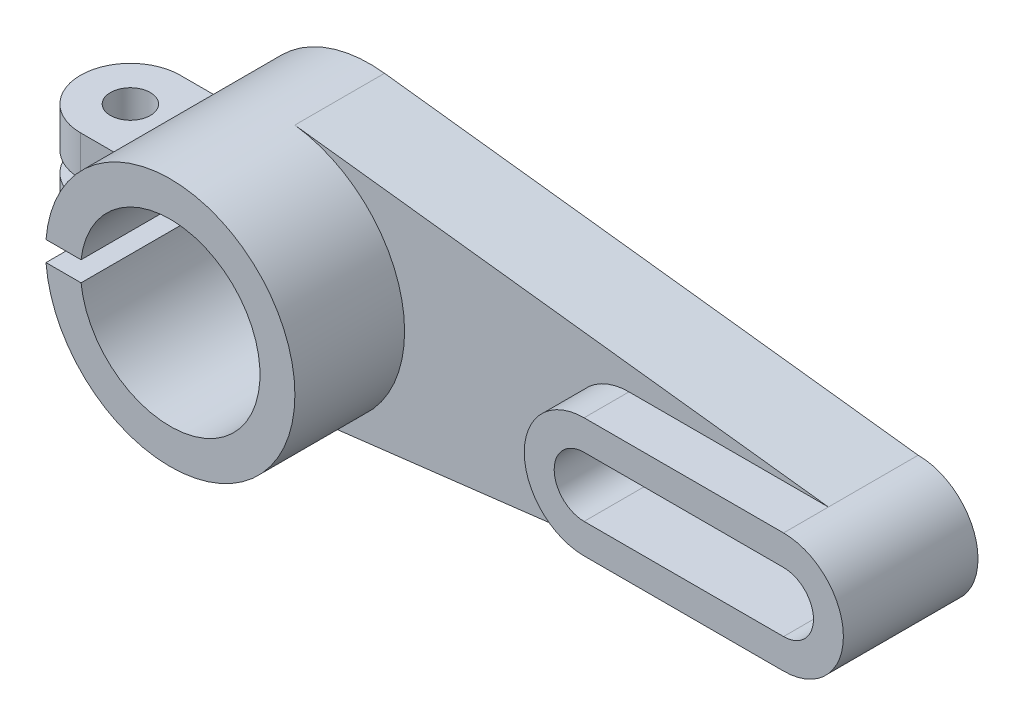
from build123d import *

# Parameters (mm, degrees)
BOSS_EXTRUDE1_DEPTH = 18
BOSS_EXTRUDE2_DEPTH = 9
CUT_EXTRUDE1_DEPTH  = 28
SKETCH3_R           = 25
SKETCH3_R_2         = 18
BOSS_EXTRUDE3_DEPTH = 22
SKETCH3_2_R         = 18
CUT_EXTRUDE2_DEPTH  = 41
SKETCH6_R           = 4
BOSS_EXTRUDE5_DEPTH = 10
SKETCH7_W           = 57.081853501
SKETCH7_H           = 4
CUT_EXTRUDE3_DEPTH  = 40


with BuildPart() as part:
    # Sketch1 → Boss-Extrude1 (new body)
    with BuildSketch(Plane.XY):
        with BuildLine():
            Line((110, 12), (2.973910519, 24.822486906))
            ThreePointArc((2.973910519, 24.822486906), (-25, 0), (2.973910519, -24.822486906))
            Line((2.973910519, -24.822486906), (110, -12))
            ThreePointArc((110, -12), (122, 0), (110, 12))
        make_face()
    extrude(amount=-BOSS_EXTRUDE1_DEPTH)

    # Sketch2 → Boss-Extrude2 (add)
    with BuildSketch(Plane.XY.offset(9)):
        with BuildLine():
            Line((110, -12), (70, -12))
            ThreePointArc((70, -12), (58, 0), (70, 12))
            Line((70, 12), (110, 12))
            ThreePointArc((110, 12), (122, 0), (110, -12))
        make_face()
        with BuildLine():
            Line((70, 6), (110, 6))
            ThreePointArc((110, 6), (116, 0), (110, -6))
            Line((110, -6), (70, -6))
            ThreePointArc((70, -6), (64, 0), (70, 6))
        make_face(mode=Mode.SUBTRACT)
    extrude(amount=-BOSS_EXTRUDE2_DEPTH)

    # Sketch2_2 → Cut-Extrude1 (cut, through all)
    with BuildSketch(Plane.XY.offset(9)):
        with BuildLine():
            Line((70, -6), (110, -6))
            ThreePointArc((110, -6), (116, 0), (110, 6))
            Line((110, 6), (70, 6))
            ThreePointArc((70, 6), (64, 0), (70, -6))
        make_face()
    extrude(amount=-CUT_EXTRUDE1_DEPTH, mode=Mode.SUBTRACT)

    # Sketch3 → Boss-Extrude3 (add)
    with BuildSketch(Plane.XY.offset(22)):
        Circle(SKETCH3_R)
        Circle(SKETCH3_R_2, mode=Mode.SUBTRACT)
    extrude(amount=-BOSS_EXTRUDE3_DEPTH)

    # Sketch3_2 → Cut-Extrude2 (cut, through all)
    with BuildSketch(Plane.XY.offset(22)):
        Circle(SKETCH3_2_R)
    extrude(amount=-CUT_EXTRUDE2_DEPTH, mode=Mode.SUBTRACT)

    # Sketch6 → Boss-Extrude5 (add, symmetric)
    with BuildSketch(Plane(origin=(0, 0, 0), x_dir=(1, 0, 0), z_dir=(0, 1, 0))):
        with BuildLine():
            Line((-19, 12), (-32, 12))
            ThreePointArc((-32, 12), (-42, 2), (-32, -8))
            Line((-32, -8), (-19, -8))
            Line((-19, -8), (-19, 12))
        make_face()
        with Locations((-32, 2)):
            Circle(SKETCH6_R, mode=Mode.SUBTRACT)
    extrude(amount=BOSS_EXTRUDE5_DEPTH, both=True)

    # Sketch7 → Cut-Extrude3 (cut)
    with BuildSketch(Plane(origin=(-42, 0, 0), x_dir=(0, 0, -1), z_dir=(1, 0, 0))):
        with Locations((1.514511954, 0)):
            Rectangle(SKETCH7_W, SKETCH7_H)
    extrude(amount=CUT_EXTRUDE3_DEPTH, mode=Mode.SUBTRACT)


solid = part.part
